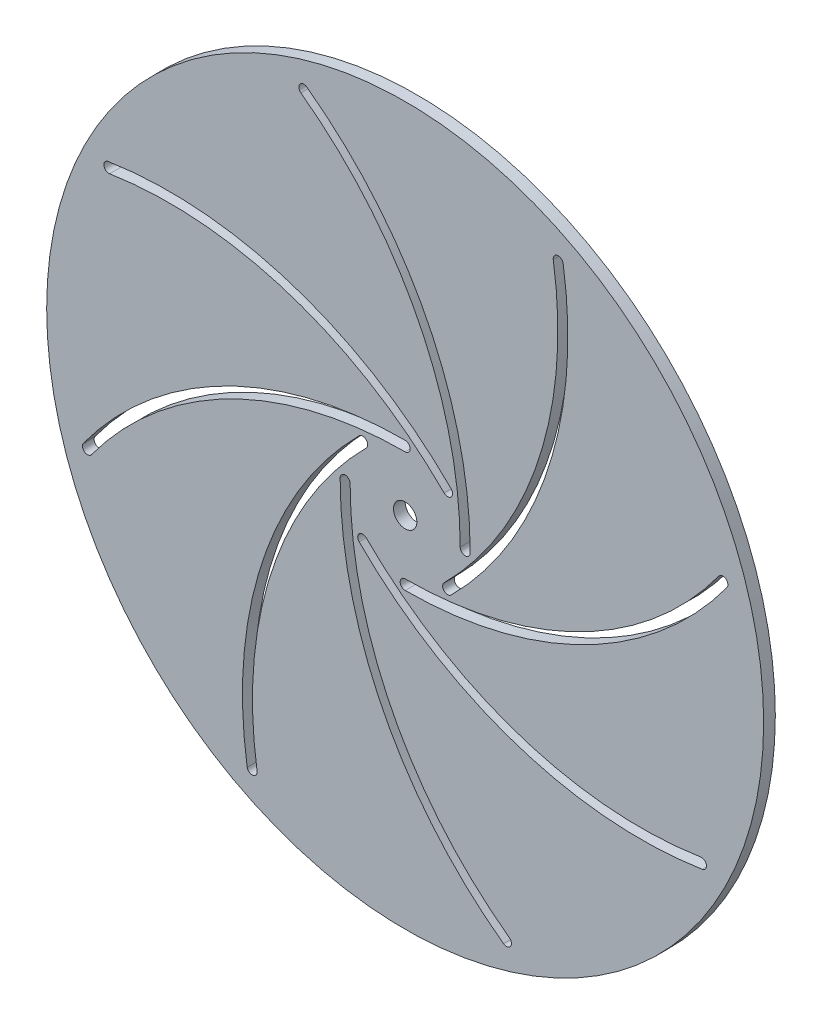
from build123d import *

# Parameters (mm, degrees)
SKETCH1_R                = 107.5
SKETCH1_R_2              = 3.5
BOSS_EXTRUDE1_DEPTH      = 1.75
BOSS_EXTRUDE1_DEPTH_BACK = 1.75


with BuildPart() as part:
    # Sketch1 → Boss-Extrude1 (new body, two sides)
    with BuildSketch(Plane.XY) as boss_extrude1_sk:
        Circle(SKETCH1_R)
        Circle(SKETCH1_R_2, mode=Mode.SUBTRACT)
        with BuildLine():
            ThreePointArc((0, 19.5), (-54.1059262, 6.549513138), (-96.484687775, -29.495))
            ThreePointArc((-96.484687775, -29.495), (-96.158582907, -31.591104867), (-94.06247804, -31.265))
            ThreePointArc((-94.06247804, -31.265), (-52.74761843, 3.874629963), (0, 16.5))
            ThreePointArc((0, 16.5), (1.5, 18), (0, 19.5))
        make_face(mode=Mode.SUBTRACT)
        with BuildLine():
            ThreePointArc((13.788582233, 13.788582233), (-33.627462165, 42.889872472), (-89.081091517, 47.368862495))
            ThreePointArc((-89.081091517, 47.368862495), (-90.33267052, 45.656101566), (-88.619909591, 44.404522563))
            ThreePointArc((-88.619909591, 44.404522563), (-34.558421561, 40.037975805), (11.66726189, 11.66726189))
            ThreePointArc((11.66726189, 11.66726189), (13.788582233, 11.66726189), (13.788582233, 13.788582233))
        make_face(mode=Mode.SUBTRACT)
        with BuildLine():
            ThreePointArc((19.5, 0), (6.549513138, 54.1059262), (-29.495, 96.484687775))
            ThreePointArc((-29.495, 96.484687775), (-31.591104867, 96.158582907), (-31.265, 94.06247804))
            ThreePointArc((-31.265, 94.06247804), (3.874629963, 52.74761843), (16.5, 0))
            ThreePointArc((16.5, 0), (18, -1.5), (19.5, 0))
        make_face(mode=Mode.SUBTRACT)
        with BuildLine():
            ThreePointArc((13.788582233, -13.788582233), (42.889872472, 33.627462165), (47.368862495, 89.081091517))
            ThreePointArc((47.368862495, 89.081091517), (45.656101566, 90.33267052), (44.404522563, 88.619909591))
            ThreePointArc((44.404522563, 88.619909591), (40.037975805, 34.558421561), (11.66726189, -11.66726189))
            ThreePointArc((11.66726189, -11.66726189), (11.66726189, -13.788582233), (13.788582233, -13.788582233))
        make_face(mode=Mode.SUBTRACT)
        with BuildLine():
            ThreePointArc((0, -19.5), (54.1059262, -6.549513138), (96.484687775, 29.495))
            ThreePointArc((96.484687775, 29.495), (96.158582907, 31.591104867), (94.06247804, 31.265))
            ThreePointArc((94.06247804, 31.265), (52.74761843, -3.874629963), (0, -16.5))
            ThreePointArc((0, -16.5), (-1.5, -18), (0, -19.5))
        make_face(mode=Mode.SUBTRACT)
        with BuildLine():
            ThreePointArc((-13.788582233, -13.788582233), (33.627462165, -42.889872472), (89.081091517, -47.368862495))
            ThreePointArc((89.081091517, -47.368862495), (90.33267052, -45.656101566), (88.619909591, -44.404522563))
            ThreePointArc((88.619909591, -44.404522563), (34.558421561, -40.037975805), (-11.66726189, -11.66726189))
            ThreePointArc((-11.66726189, -11.66726189), (-13.788582233, -11.66726189), (-13.788582233, -13.788582233))
        make_face(mode=Mode.SUBTRACT)
        with BuildLine():
            ThreePointArc((-19.5, 0), (-6.549513138, -54.1059262), (29.495, -96.484687775))
            ThreePointArc((29.495, -96.484687775), (31.591104867, -96.158582907), (31.265, -94.06247804))
            ThreePointArc((31.265, -94.06247804), (-3.874629963, -52.74761843), (-16.5, 0))
            ThreePointArc((-16.5, 0), (-18, 1.5), (-19.5, 0))
        make_face(mode=Mode.SUBTRACT)
        with BuildLine():
            ThreePointArc((-13.788582233, 13.788582233), (-42.889872472, -33.627462165), (-47.368862495, -89.081091517))
            ThreePointArc((-47.368862495, -89.081091517), (-45.656101566, -90.33267052), (-44.404522563, -88.619909591))
            ThreePointArc((-44.404522563, -88.619909591), (-40.037975805, -34.558421561), (-11.66726189, 11.66726189))
            ThreePointArc((-11.66726189, 11.66726189), (-11.66726189, 13.788582233), (-13.788582233, 13.788582233))
        make_face(mode=Mode.SUBTRACT)
    extrude(amount=BOSS_EXTRUDE1_DEPTH)
    extrude(boss_extrude1_sk.sketch, amount=-BOSS_EXTRUDE1_DEPTH_BACK)


solid = part.part
